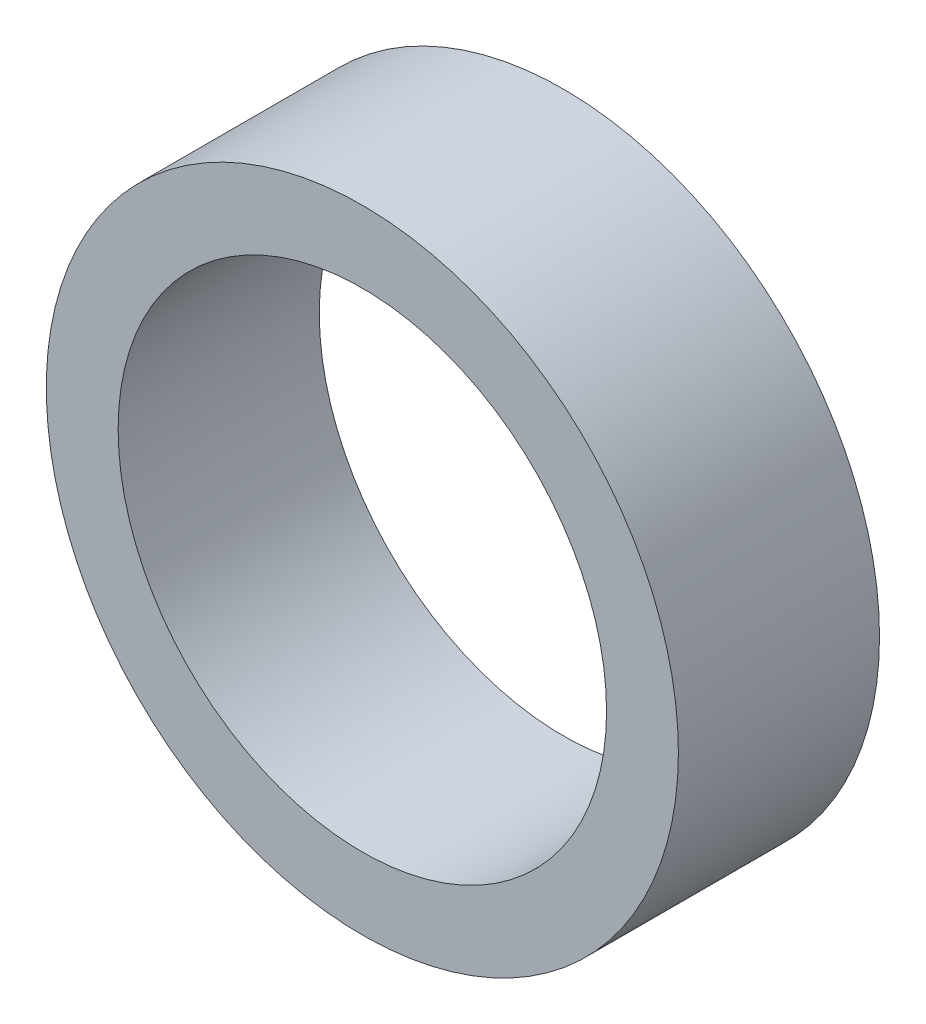
from build123d import *

# Parameters (mm, degrees)
SKETCH1_R           = 11
SKETCH1_R_2         = 8.5
BOSS_EXTRUDE1_DEPTH = 7


with BuildPart() as part:
    # Sketch1 → Boss-Extrude1 (new body)
    with BuildSketch(Plane.XY):
        Circle(SKETCH1_R)
        Circle(SKETCH1_R_2, mode=Mode.SUBTRACT)
    extrude(amount=BOSS_EXTRUDE1_DEPTH)


solid = part.part
